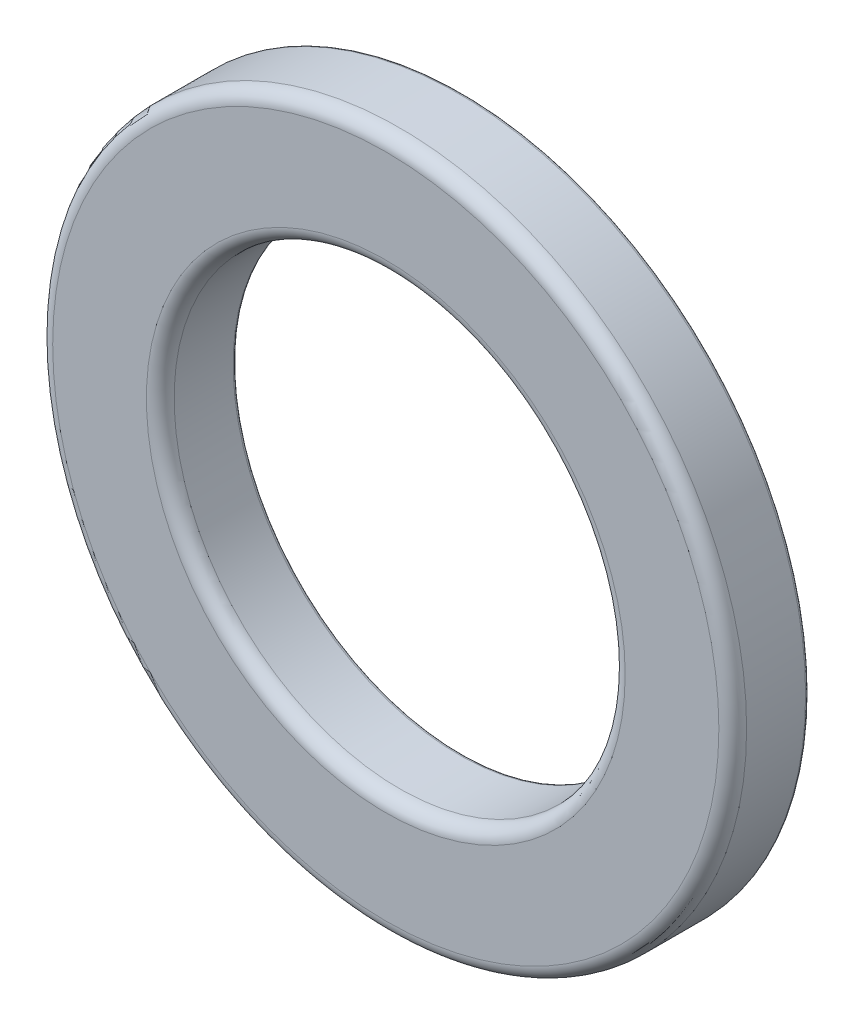
from build123d import *

# Parameters (mm, degrees)
SKETCH3_R                = 10
SKETCH3_R_2              = 6.5
BOSS_EXTRUDE1_DEPTH      = 1.1
BOSS_EXTRUDE1_DEPTH_BACK = 1.1
FILLET1_R                = 0.4
FILLET2_R                = 0.1


with BuildPart() as part:
    # Sketch3 → Boss-Extrude1 (new body, two sides)
    with BuildSketch(Plane.XY) as boss_extrude1_sk:
        Circle(SKETCH3_R)
        Circle(SKETCH3_R_2, mode=Mode.SUBTRACT)
    extrude(amount=BOSS_EXTRUDE1_DEPTH)
    extrude(boss_extrude1_sk.sketch, amount=-BOSS_EXTRUDE1_DEPTH_BACK)

    # Fillet1
    fillet1_edges = [part.edges().sort_by_distance(p)[0] for p in [
        (-10, 0, 1.1),
        (-6.5, 0, 1.1),
    ]]
    fillet(fillet1_edges, radius=FILLET1_R)

    # Fillet2
    fillet2_edges = [part.edges().sort_by_distance(p)[0] for p in [
        (-10, 0, -1.1),
        (-6.5, 0, -1.1),
    ]]
    fillet(fillet2_edges, radius=FILLET2_R)


solid = part.part
